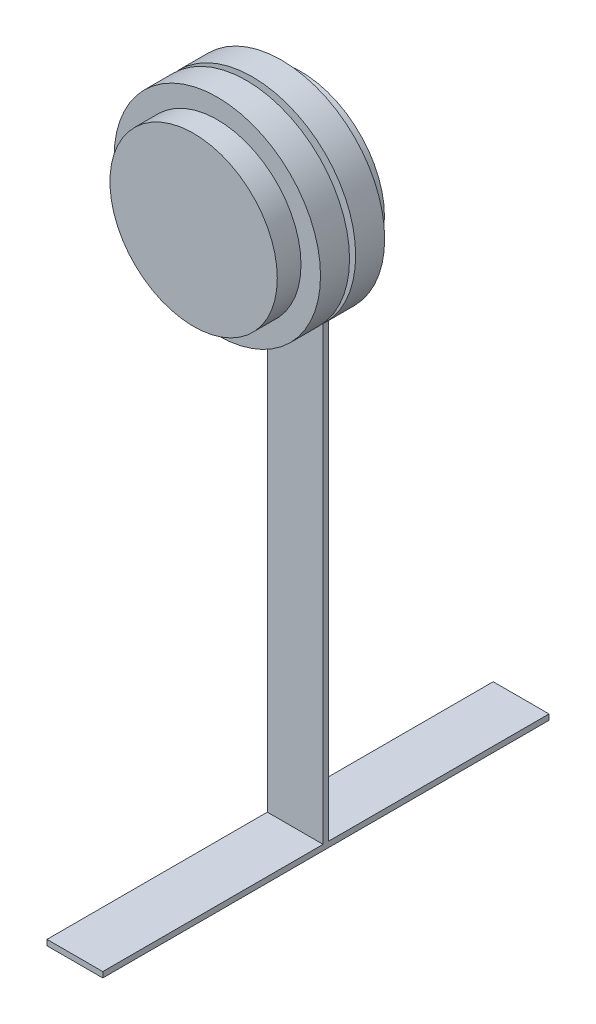
from build123d import *

# Parameters (mm, degrees)
SKETCH1_R                = 38.1
HUB_CENTER_DEPTH         = 25.4
HUB_CENTER_DEPTH_BACK    = 23.4
INNER_START              = 1.397
SKETCH2_R                = 46.99
INNER_BEARING_DEPTH      = 13.208
OUTER_START              = -1.397
SKETCH3_R                = 46.99
OUTER_BEARING_DEPTH      = 13.208
TIRE_ARM_DEPTH           = 2.54
SKETCH5_W                = 25.4
SKETCH5_H                = 203.2
TIRE_CONTACT_PATCH_DEPTH = 2.54


with BuildPart() as part:
    # Sketch1 → Hub Center (new body, two sides)
    with BuildSketch(Plane.XY) as hub_center_sk:
        Circle(SKETCH1_R)
    extrude(amount=HUB_CENTER_DEPTH)
    extrude(hub_center_sk.sketch, amount=-HUB_CENTER_DEPTH_BACK)

    # Sketch2 → Inner Bearing (add)
    with BuildSketch(Plane.XY.offset(INNER_START)):
        Circle(SKETCH2_R)
    extrude(amount=INNER_BEARING_DEPTH)

    # Sketch3 → Outer Bearing (add)
    with BuildSketch(Plane.XY.offset(OUTER_START)):
        Circle(SKETCH3_R)
    extrude(amount=-OUTER_BEARING_DEPTH)

    # Sketch4 → Tire Arm (add)
    with BuildSketch(Plane(origin=(0, 0, -23.4), x_dir=(-1, 0, 0), z_dir=(0, 0, -1))):
        with BuildLine():
            Line((-12.7, -35.921024484), (-12.7, -261.62))
            Line((-12.7, -261.62), (12.7, -261.62))
            Line((12.7, -261.62), (12.7, -35.921024484))
            ThreePointArc((12.7, -35.921024484), (0, -38.1), (-12.7, -35.921024484))
        make_face()
    extrude(amount=-TIRE_ARM_DEPTH)

    # Sketch5 → Tire Contact Patch (add)
    with BuildSketch(Plane.XZ.offset(261.62)):
        with Locations((0, -22.13)):
            Rectangle(SKETCH5_W, SKETCH5_H)
    extrude(amount=-TIRE_CONTACT_PATCH_DEPTH)


solid = part.part
